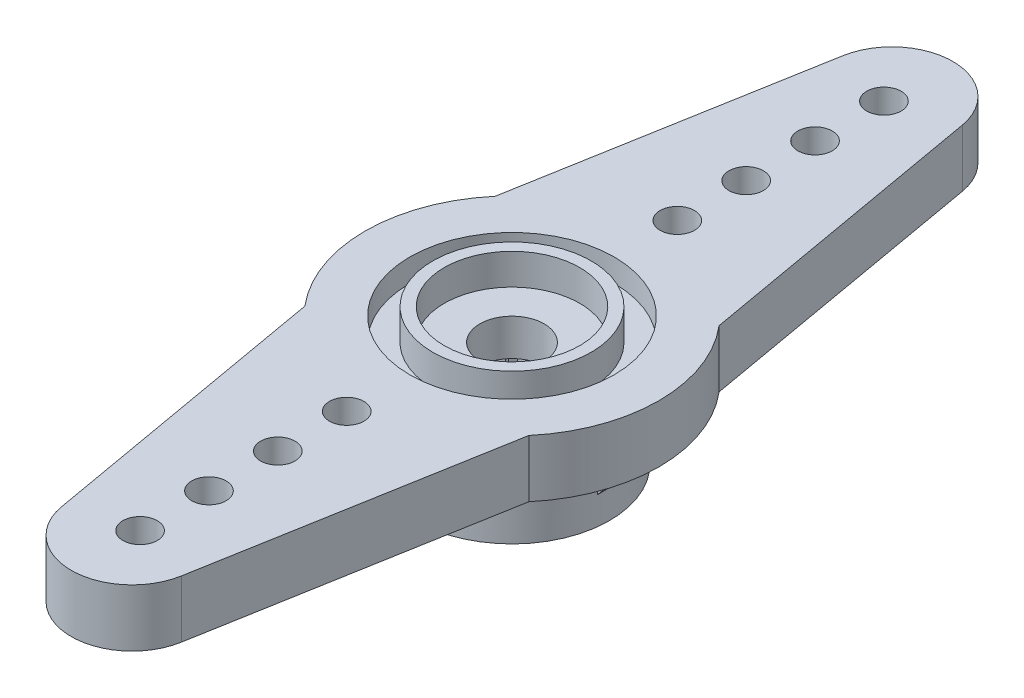
from build123d import *

# Parameters (mm, degrees)
BASES_R                     = 6.4
BASE_DEPTH                  = 5.6
TOPBORES_R                  = 1.4
TOP_BORE_DEPTH              = 11.643307757
HORN_HALF_DEPTH             = 2.5
HORNATTACHS_R               = 0.75
HORN_ATTACH_DEPTH           = 21.999047597
HA_LP_COUNT                 = 4
HA_LP_PITCH                 = 3
HORN_BODIES_COPY_1_SKETCH_R = 0.75
HORN_BODIES_COPY_1_DEPTH    = 21.999047597
HORN_BODIES_COPY_2_SKETCH_R = 0.75
HORN_BODIES_COPY_2_DEPTH    = 21.999047597
HORN_BODIES_COPY_3_SKETCH_R = 0.75
HORN_BODIES_COPY_3_DEPTH    = 21.999047597
TOOTH_DEPTH                 = 3
TOOTH_CP_COUNT              = 26
BOTTOMBORES_R               = 2.6
BOTTOM_BORE_DEPTH           = 3
HOLDINGSHAFTS_R             = 6.4
HOLDINGSHAFTS_R_2           = 4.25
HOLDING_SHAFT_DEPTH         = 3.1
RIB_DEPTH                   = 0.5
RIB_CP_COUNT                = 4
TOPCUTS_R                   = 4.45
TOP_CUT_DEPTH               = 1
TOPPOCKETCYLINDERS_R        = 3.45
TOPPOCKETCYLINDERS_R_2      = 2.95
TOP_POCKET_CYLINDER_DEPTH   = 1.35


with BuildPart() as part:
    # BaseS → BASE (new body)
    with BuildSketch(Plane(origin=(0, 0, 0), x_dir=(1, 0, 0), z_dir=(0, 1, 0))):
        with Locations(Location((0, 0, 0), (0, 0, 270))):
            Circle(BASES_R)
    extrude(amount=BASE_DEPTH)

    # TopBoreS → TOP BORE (cut, through all)
    with BuildSketch(Plane(origin=(0, 5.6, 0), x_dir=(1, 0, 0), z_dir=(0, 1, 0))):
        with Locations(Location((0, 0, 0), (0, 0, 270))):
            Circle(TOPBORES_R)
    extrude(amount=-TOP_BORE_DEPTH, mode=Mode.SUBTRACT)

    # HornHalfS → HORN HALF (add)
    with BuildSketch(Plane(origin=(0, 5.6, 0), x_dir=(1, 0, 0), z_dir=(0, 1, 0))):
        with BuildLine():
            Line((-2.609740545, 17.010167671), (-4.878700663, 4.142255405))
            ThreePointArc((-4.878700663, 4.142255405), (0, 6.4), (4.878700663, 4.142255405))
            Line((4.878700663, 4.142255405), (2.609740545, 17.010167671))
            ThreePointArc((2.609740545, 17.010167671), (0, 19.2), (-2.609740545, 17.010167671))
        make_face()
    horn_half = extrude(amount=-HORN_HALF_DEPTH)

    # HornAttachS → HORN ATTACH (cut, through all)
    with BuildSketch(Plane(origin=(0, 5.6, 0), x_dir=(1, 0, 0), z_dir=(0, 1, 0))):
        with Locations(Location((0, 16.2, 0), (0, 0, 270))):
            Circle(HORNATTACHS_R)
    horn_attach = extrude(amount=-HORN_ATTACH_DEPTH, mode=Mode.SUBTRACT)

    # HA LP: HORN ATTACH ×4
    with Locations(*[(0, 0, i * HA_LP_PITCH) for i in range(1, HA_LP_COUNT)]):
        add(horn_attach, mode=Mode.SUBTRACT)

    # HORN BODIES: HORN HALF, HORN ATTACH across plane
    add(horn_half.mirror(Plane.XY))
    add(horn_attach.mirror(Plane.XY), mode=Mode.SUBTRACT)

    # HORN BODIES copy 1 sketch → HORN BODIES copy 1 (cut, through all)
    with BuildSketch(Plane(origin=(0, 5.6, -3), x_dir=(1, 0, 0), z_dir=(0, 1, 0))):
        with Locations((0, -16.2)):
            Circle(HORN_BODIES_COPY_1_SKETCH_R)
    extrude(amount=-HORN_BODIES_COPY_1_DEPTH, mode=Mode.SUBTRACT)

    # HORN BODIES copy 2 sketch → HORN BODIES copy 2 (cut, through all)
    with BuildSketch(Plane(origin=(0, 5.6, -6), x_dir=(1, 0, 0), z_dir=(0, 1, 0))):
        with Locations((0, -16.2)):
            Circle(HORN_BODIES_COPY_2_SKETCH_R)
    extrude(amount=-HORN_BODIES_COPY_2_DEPTH, mode=Mode.SUBTRACT)

    # HORN BODIES copy 3 sketch → HORN BODIES copy 3 (cut, through all)
    with BuildSketch(Plane(origin=(0, 5.6, -9), x_dir=(1, 0, 0), z_dir=(0, 1, 0))):
        with Locations((0, -16.2)):
            Circle(HORN_BODIES_COPY_3_SKETCH_R)
    extrude(amount=-HORN_BODIES_COPY_3_DEPTH, mode=Mode.SUBTRACT)

    # ToothS → TOOTH (cut)
    with BuildSketch(Plane.XZ):
        with BuildLine():
            Line((0, -2.9), (0.262912611, -2.586672952))
            ThreePointArc((0.262912611, -2.586672952), (0, -2.6), (-0.262912611, -2.586672952))
            Line((-0.262912611, -2.586672952), (0, -2.9))
        make_face()
    tooth = extrude(amount=-TOOTH_DEPTH, mode=Mode.SUBTRACT)

    # TOOTH CP: TOOTH ×26 about axis
    tooth_cp_axis = Axis((0, 0, 0), (0, 1, 0))
    for i in range(1, TOOTH_CP_COUNT):
        add(tooth.rotate(tooth_cp_axis, i * 360 / TOOTH_CP_COUNT), mode=Mode.SUBTRACT)

    # BottomBoreS → BOTTOM BORE (cut)
    with BuildSketch(Plane(origin=(0, 0, 0), x_dir=(-1, 0, 0), z_dir=(0, -1, 0))):
        Circle(BOTTOMBORES_R)
    extrude(amount=-BOTTOM_BORE_DEPTH, mode=Mode.SUBTRACT)

    # HoldingShaftS → HOLDING SHAFT (cut)
    with BuildSketch(Plane.XZ):
        Circle(HOLDINGSHAFTS_R)
        with Locations(Location((0, 0, 0), (0, 0, 270))):
            Circle(HOLDINGSHAFTS_R_2, mode=Mode.SUBTRACT)
    extrude(amount=-HOLDING_SHAFT_DEPTH, mode=Mode.SUBTRACT)

    # RibS → RIB (add, symmetric)
    with BuildSketch(Plane.XY):
        Polygon((4.21, 1.2), (5.804289299, 3.1), (4.21, 3.1), (4.16, 3.1), (4.16, 1.2), align=None)
    rib = extrude(amount=RIB_DEPTH, both=True)

    # RIB CP: RIB ×4 about axis
    rib_cp_axis = Axis((0, 0, 0), (0, 1, 0))
    for i in range(1, RIB_CP_COUNT):
        add(rib.rotate(rib_cp_axis, i * 360 / RIB_CP_COUNT))

    # TopCutS → TOP CUT (cut)
    with BuildSketch(Plane(origin=(0, 5.6, 0), x_dir=(1, 0, 0), z_dir=(0, 1, 0))):
        with Locations(Location((0, 0, 0), (0, 0, 270))):
            Circle(TOPCUTS_R)
    extrude(amount=-TOP_CUT_DEPTH, mode=Mode.SUBTRACT)

    # TopPocketCylinderS → TOP POCKET CYLINDER (add)
    with BuildSketch(Plane(origin=(0, 4.6, 0), x_dir=(1, 0, 0), z_dir=(0, 1, 0))):
        with Locations(Location((0, 0, 0), (0, 0, 270))):
            Circle(TOPPOCKETCYLINDERS_R)
        with Locations(Location((0, 0, 0), (0, 0, 270))):
            Circle(TOPPOCKETCYLINDERS_R_2, mode=Mode.SUBTRACT)
    extrude(amount=TOP_POCKET_CYLINDER_DEPTH)


solid = part.part
